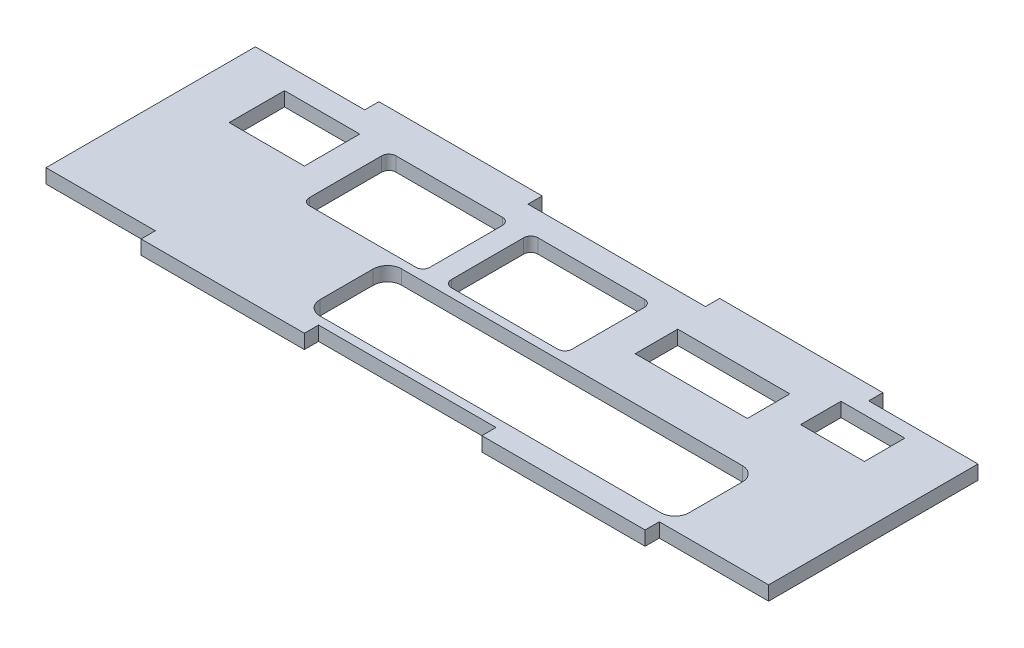
from build123d import *

# Parameters (mm, degrees)
SKETCH_1_W                     = 101.8
SKETCH_1_H                     = 29.5
EXTRUDE_1_DEPTH                = 2
SKETCH_2_W                     = 23
SKETCH_2_H                     = 2
EXTRUDE_2_DEPTH                = 2
SKETCH_3_W                     = 9
SKETCH_3_H                     = 5.7
CUT_EXTRUDE_1_DEPTH            = 3
SKETCH_4_W                     = 10.6
SKETCH_4_H                     = 7.8
CUT_EXTRUDE_2_DEPTH            = 3
SKETCH_6_W                     = 17
SKETCH_6_H                     = 12.2
CUT_EXTRUDE_4_DEPTH            = 3
FILLET_1_R                     = 1
PATTERN_LINEAR_1_COUNT         = 2
PATTERN_LINEAR_1_PITCH         = 20
FILLET_1_OF_PATTERN_LINEAR_1_R = 1
SKETCH_7_W                     = 15.8
SKETCH_7_H                     = 6
CUT_EXTRUDE_5_DEPTH            = 3
CUT_EXTRUDE_6_DEPTH            = 3


with BuildPart() as part:
    # 草图1 → 凸台-拉伸1 (new body)
    with BuildSketch(Plane(origin=(0, 0, 0), x_dir=(1, 0, 0), z_dir=(0, 1, 0))):
        Rectangle(SKETCH_1_W, SKETCH_1_H)
    extrude(amount=EXTRUDE_1_DEPTH)

    # 草图2 → 凸台-拉伸2 (add)
    with BuildSketch(Plane(origin=(0, 2, 0), x_dir=(1, 0, 0), z_dir=(0, 1, 0))):
        with Locations((-24, 15.75)):
            Rectangle(SKETCH_2_W, SKETCH_2_H)
        with Locations((24, 15.75)):
            Rectangle(SKETCH_2_W, SKETCH_2_H)
        with Locations((24, -15.75)):
            Rectangle(SKETCH_2_W, SKETCH_2_H)
        with Locations((-24, -15.75)):
            Rectangle(SKETCH_2_W, SKETCH_2_H)
    extrude(amount=-EXTRUDE_2_DEPTH)

    # 草图3 → 切除-拉伸1 (cut, through all)
    with BuildSketch(Plane(origin=(0, 2, 0), x_dir=(1, 0, 0), z_dir=(0, 1, 0))):
        with Locations((38.1, 9.9)):
            Rectangle(SKETCH_3_W, SKETCH_3_H)
    extrude(amount=-CUT_EXTRUDE_1_DEPTH, mode=Mode.SUBTRACT)

    # 草图4 → 切除-拉伸2 (cut, through all)
    with BuildSketch(Plane(origin=(0, 2, 0), x_dir=(1, 0, 0), z_dir=(0, 1, 0))):
        with Locations((-38.2, 7.55)):
            Rectangle(SKETCH_4_W, SKETCH_4_H)
    extrude(amount=-CUT_EXTRUDE_2_DEPTH, mode=Mode.SUBTRACT)

    # 草图6 → 切除-拉伸4 (cut, through all)
    with BuildSketch(Plane(origin=(0, 2, 0), x_dir=(1, 0, 0), z_dir=(0, 1, 0))):
        with Locations((-20.2, 5.25)):
            Rectangle(SKETCH_6_W, SKETCH_6_H)
    cut_extrude_4 = extrude(amount=-CUT_EXTRUDE_4_DEPTH, mode=Mode.SUBTRACT)

    # 圆角1
    fillet_1_edges = [part.edges().sort_by_distance(p)[0] for p in [
        (-28.7, 1, 0.85),
        (-28.7, 1, -11.35),
        (-11.7, 1, -11.35),
        (-11.7, 1, 0.85),
    ]]
    fillet(fillet_1_edges, radius=FILLET_1_R)

    # 阵列(线性)1: 切除-拉伸4 ×2
    with Locations(*[(i * PATTERN_LINEAR_1_PITCH, 0, 0) for i in range(1, PATTERN_LINEAR_1_COUNT)]):
        add(cut_extrude_4, mode=Mode.SUBTRACT)

    # 圆角1 of 阵列(线性)1
    fillet_1_of_pattern_linear_1_edges = [part.edges().sort_by_distance(p)[0] for p in [
        (-8.7, 1, 0.85),
        (-8.7, 1, -11.35),
        (8.3, 1, -11.35),
        (8.3, 1, 0.85),
    ]]
    fillet(fillet_1_of_pattern_linear_1_edges, radius=FILLET_1_OF_PATTERN_LINEAR_1_R)

    # 草图7 → 切除-拉伸5 (cut, through all)
    with BuildSketch(Plane(origin=(0, 2, 0), x_dir=(1, 0, 0), z_dir=(0, 1, 0))):
        with Locations((21.2, 7.05)):
            Rectangle(SKETCH_7_W, SKETCH_7_H)
    extrude(amount=-CUT_EXTRUDE_5_DEPTH, mode=Mode.SUBTRACT)

    # 草图8 → 切除-拉伸6 (cut, through all)
    with BuildSketch(Plane(origin=(0, 2, 0), x_dir=(1, 0, 0), z_dir=(0, 1, 0))):
        with BuildLine():
            Line((-13.5, -2.05), (34.5, -2.05))
            ThreePointArc((34.5, -2.05), (35.914213562, -2.635786438), (36.5, -4.05))
            Line((36.5, -4.05), (36.5, -11.55))
            ThreePointArc((36.5, -11.55), (35.914213562, -12.964213562), (34.5, -13.55))
            Line((34.5, -13.55), (-13.5, -13.55))
            ThreePointArc((-13.5, -13.55), (-14.914213562, -12.964213562), (-15.5, -11.55))
            Line((-15.5, -11.55), (-15.5, -4.05))
            ThreePointArc((-15.5, -4.05), (-14.914213562, -2.635786438), (-13.5, -2.05))
        make_face()
    extrude(amount=-CUT_EXTRUDE_6_DEPTH, mode=Mode.SUBTRACT)


solid = part.part
